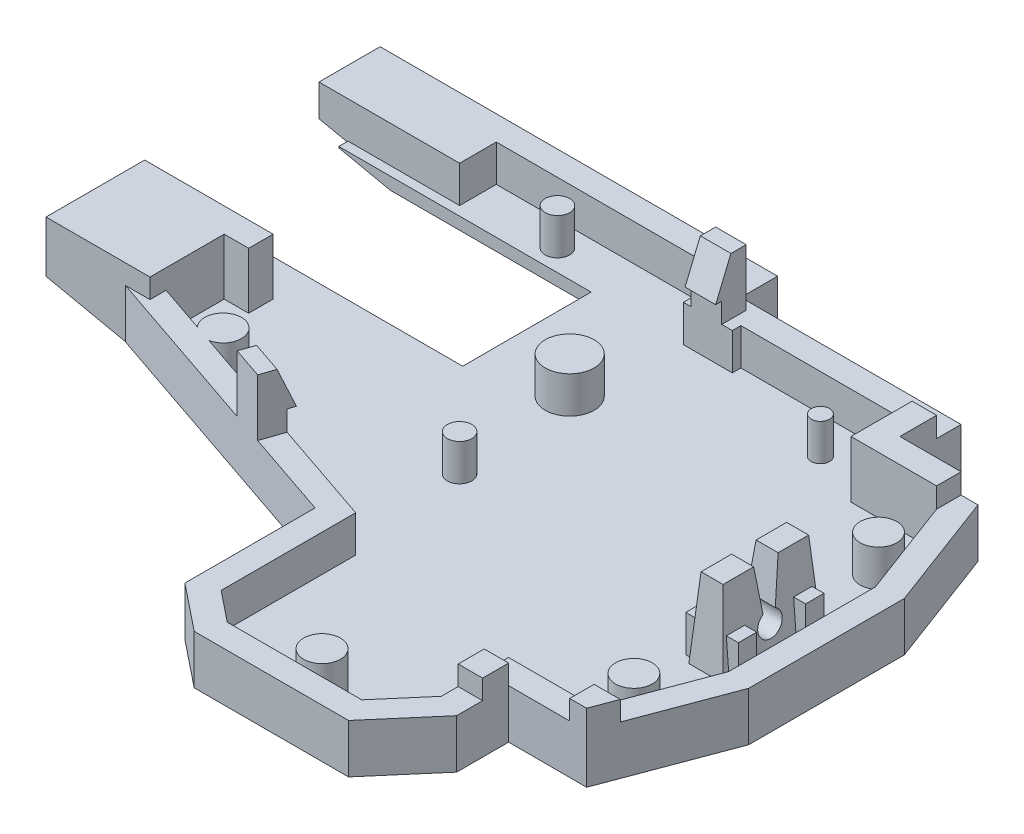
from build123d import *

# Parameters (mm, degrees)
SKETCH13_W           = 50
SKETCH13_H           = 45
BOSS_EXTRUDE4_DEPTH  = 1.6
SKETCH14_W           = 10
SKETCH14_H           = 8
CUT_EXTRUDE6_DEPTH   = 2.6
SKETCH15_W           = 18
SKETCH15_H           = 3
CUT_EXTRUDE7_DEPTH   = 2.6
SKETCH16_W           = 4
SKETCH16_H           = 0.7
CUT_EXTRUDE8_DEPTH   = 2.6
CUT_EXTRUDE9_DEPTH   = 2.6
SKETCH18_W           = 21.109590793
SKETCH18_H           = 22.840524871
CUT_EXTRUDE10_DEPTH  = 2.6
CUT_EXTRUDE11_DEPTH  = 2.6
SKETCH22_W           = 2
SKETCH22_H           = 3
CUT_EXTRUDE12_DEPTH  = 2.6
CUT_EXTRUDE13_DEPTH  = 2.6
CUT_EXTRUDE14_DEPTH  = 2.6
SKETCH25_W           = 2.8
SKETCH25_H           = 8
CUT_EXTRUDE15_DEPTH  = 2.6
BOSS_EXTRUDE6_DEPTH  = 6
SKETCH30_W           = 2.8
SKETCH30_H           = 8
BOSS_EXTRUDE7_DEPTH  = 3.5
CUT_EXTRUDE16_DEPTH  = 4.6
SKETCH32_W           = 2.8
SKETCH32_H           = 8
BOSS_EXTRUDE8_DEPTH  = 4.6
CUT_EXTRUDE18_DEPTH  = 4.6
SKETCH37_R           = 1
CUT_EXTRUDE19_DEPTH  = 4.6
CUT_EXTRUDE20_DEPTH  = 4.6
CUT_EXTRUDE21_START  = 6
CUT_EXTRUDE21_DEPTH  = 20.059798
BOSS_EXTRUDE9_DEPTH  = 4.6
SKETCH44_W           = 4.3
SKETCH44_H           = 1.5
BOSS_EXTRUDE11_DEPTH = 3
SKETCH45_R           = 1.5
SKETCH45_R_2         = 1
SKETCH45_R_3         = 1.999622229
SKETCH45_R_4         = 1.503341979
SKETCH45_R_5         = 0.75
BOSS_EXTRUDE12_DEPTH = 3
SKETCH46_W           = 2.5
SKETCH46_H           = 2
SKETCH46_W_2         = 2
BOSS_EXTRUDE13_DEPTH = 1.65
SKETCH47_W           = 3
SKETCH47_H           = 3
BOSS_EXTRUDE14_DEPTH = 3
SKETCH48_W           = 2
SKETCH48_H           = 16.336241737
CUT_EXTRUDE22_DEPTH  = 3
SKETCH49_W           = 21.336241737
SKETCH49_H           = 3
BOSS_EXTRUDE15_DEPTH = 13
SKETCH50_W           = 67
SKETCH50_H           = 49
BOSS_EXTRUDE16_DEPTH = 3
SKETCH51_W           = 5
SKETCH51_H           = 11
BOSS_EXTRUDE17_DEPTH = 15.6
CUT_EXTRUDE23_DEPTH  = 1.65
SKETCH53_W           = 2
SKETCH53_H           = 2.129349353
BOSS_EXTRUDE18_DEPTH = 1.6
SKETCH55_W           = 2.5
SKETCH55_H           = 2.5
BOSS_EXTRUDE20_DEPTH = 3
CUT_EXTRUDE24_DEPTH  = 3
SKETCH58_W           = 20
SKETCH58_H           = 10.5
SKETCH58_W_2         = 2
SKETCH58_H_2         = 2
CUT_EXTRUDE29_DEPTH  = 1
BOSS_EXTRUDE21_DEPTH = 3
BOSS_EXTRUDE22_REACH = 41.731
SKETCH61_W           = 2.5
SKETCH61_H           = 1.65
CUT_EXTRUDE30_DEPTH  = 3
CUT_EXTRUDE31_REACH  = 43.731
SKETCH64_W           = 2.551500858
SKETCH64_H           = 4.310788114
CUT_EXTRUDE32_DEPTH  = 4.65
SKETCH65_W           = 2
SKETCH65_H           = 2
BOSS_EXTRUDE23_DEPTH = 4
SKETCH66_W           = 2
SKETCH66_H           = 2
BOSS_EXTRUDE24_DEPTH = 1.6
SKETCH67_W           = 2.5
SKETCH67_H           = 2
BOSS_EXTRUDE25_DEPTH = 3
CUT_EXTRUDE33_DEPTH  = 3
BOSS_EXTRUDE26_DEPTH = 1.65
SKETCH70_W           = 5.055009343
SKETCH70_H           = 5.560438358
CUT_EXTRUDE34_DEPTH  = 3
BOSS_EXTRUDE27_DEPTH = 3
CUT_EXTRUDE35_DEPTH  = 3
BOSS_EXTRUDE28_REACH = 39.863
CUT_EXTRUDE36_DEPTH  = 3
FILLET8_R            = 1
SKETCH76_W           = 7
SKETCH76_H           = 14.5
BOSS_EXTRUDE29_DEPTH = 14.5
BOSS_EXTRUDE30_DEPTH = 2
CUT_EXTRUDE37_DEPTH  = 2
BOSS_EXTRUDE31_DEPTH = 2.684479
SKETCH85_W           = 30.566158209
SKETCH85_H           = 1.725230041
BOSS_EXTRUDE33_DEPTH = 3
BOSS_EXTRUDE34_DEPTH = 3
BOSS_EXTRUDE35_DEPTH = 3
SKETCH88_W           = 27.09375
SKETCH88_H           = 14.5
BOSS_EXTRUDE36_DEPTH = 1.6
SKETCH90_W           = 7
SKETCH90_H           = 14.5
BOSS_EXTRUDE37_DEPTH = 1.6
SKETCH93_W           = 5
SKETCH93_H           = 11
BOSS_EXTRUDE38_DEPTH = 0.5
SKETCH94_W           = 8.605758832
SKETCH94_H           = 2
BOSS_EXTRUDE39_DEPTH = 15.6
SKETCH96_W           = 8.605758832
SKETCH96_H           = 2
BOSS_EXTRUDE40_DEPTH = 0.5
SKETCH97_W           = 2
SKETCH97_H           = 49
BOSS_EXTRUDE41_DEPTH = 19.1
SKETCH98_W           = 69
SKETCH98_H           = 2
BOSS_EXTRUDE42_DEPTH = 19.1
SKETCH99_W           = 2
SKETCH99_H           = 3
BOSS_EXTRUDE43_DEPTH = 2.087376
SKETCH100_W          = 2
SKETCH100_H          = 51
BOSS_EXTRUDE45_DEPTH = 19.1
SKETCH101_W          = 71
SKETCH101_H          = 2
BOSS_EXTRUDE46_DEPTH = 19.1
BOSS_EXTRUDE47_DEPTH = 16.1
BOSS_EXTRUDE48_DEPTH = 16.1
FILLET9_R            = 2
SKETCH105_OUTSIDE_W  = 91.128
SKETCH105_OUTSIDE_H  = 73.128
CUT_EXTRUDE38_DEPTH  = 3
SKETCH106_W          = 77.0560479
SKETCH106_H          = 58.523580684
CUT_EXTRUDE39_DEPTH  = 20.1
SKETCH107_W          = 13.37564089
SKETCH107_H          = 6.179627402
CUT_EXTRUDE40_DEPTH  = 11.5
CUT_EXTRUDE41_DEPTH  = 4
SKETCH114_W          = 66.336817547
SKETCH114_H          = 51.668552302
CUT_EXTRUDE42_DEPTH  = 2
BOSS_EXTRUDE49_DEPTH = 6.5
SKETCH116_W          = 0.628599621
SKETCH116_H          = 10.5
CUT_EXTRUDE43_DEPTH  = 6.5
SKETCH117_W          = 8.5
SKETCH117_H          = 8.070282703
BOSS_EXTRUDE50_DEPTH = 1.6
SKETCH121_W          = 19.441580634
SKETCH121_H          = 74.526099825
CUT_EXTRUDE44_DEPTH  = 2.369406641


with BuildPart() as part:
    # Sketch13 → Boss-Extrude4 (new body)
    with BuildSketch(Plane(origin=(0, 0, 0), x_dir=(1, 0, 0), z_dir=(0, 1, 0))):
        with Locations((25, -22.5)):
            Rectangle(SKETCH13_W, SKETCH13_H)
    extrude(amount=BOSS_EXTRUDE4_DEPTH)

    # Sketch14 → Cut-Extrude6 (cut, through all)
    with BuildSketch(Plane(origin=(0, 1.6, 0), x_dir=(1, 0, 0), z_dir=(0, 1, 0))):
        with Locations((45, -4)):
            Rectangle(SKETCH14_W, SKETCH14_H)
    extrude(amount=-CUT_EXTRUDE6_DEPTH, mode=Mode.SUBTRACT)

    # Sketch15 → Cut-Extrude7 (cut, through all)
    with BuildSketch(Plane(origin=(0, 1.6, 0), x_dir=(1, 0, 0), z_dir=(0, 1, 0))):
        with Locations((31, -1.5)):
            Rectangle(SKETCH15_W, SKETCH15_H)
    extrude(amount=-CUT_EXTRUDE7_DEPTH, mode=Mode.SUBTRACT)

    # Sketch16 → Cut-Extrude8 (cut, through all)
    with BuildSketch(Plane(origin=(0, 1.6, 0), x_dir=(1, 0, 0), z_dir=(0, 1, 0))):
        with Locations((24, -3.35)):
            Rectangle(SKETCH16_W, SKETCH16_H)
    extrude(amount=-CUT_EXTRUDE8_DEPTH, mode=Mode.SUBTRACT)

    # Sketch17 → Cut-Extrude9 (cut, through all)
    with BuildSketch(Plane(origin=(0, 1.6, 0), x_dir=(1, 0, 0), z_dir=(0, 1, 0))):
        Polygon((47, -8), (50, -16), (65.881056194, -16), (65.881056194, 17.957346821), (47, 17.957346821), align=None)
    extrude(amount=-CUT_EXTRUDE9_DEPTH, mode=Mode.SUBTRACT)

    # Sketch18 → Cut-Extrude10 (cut, through all)
    with BuildSketch(Plane(origin=(0, 1.6, 0), x_dir=(1, 0, 0), z_dir=(0, 1, 0))):
        with Locations((50.554795396, -47.420262436)):
            Rectangle(SKETCH18_W, SKETCH18_H)
    extrude(amount=-CUT_EXTRUDE10_DEPTH, mode=Mode.SUBTRACT)

    # Sketch21 → Cut-Extrude11 (cut, through all)
    with BuildSketch(Plane(origin=(0, 1.6, 0), x_dir=(1, 0, 0), z_dir=(0, 1, 0))):
        Polygon((50, -28), (47, -36), (47, -49.297594069), (75.196774358, -49.297594069), (75.196774358, -28), align=None)
    extrude(amount=-CUT_EXTRUDE11_DEPTH, mode=Mode.SUBTRACT)

    # Sketch22 → Cut-Extrude12 (cut, through all)
    with BuildSketch(Plane(origin=(0, 1.6, 0), x_dir=(1, 0, 0), z_dir=(0, 1, 0))):
        with Locations((1, -20.836241737)):
            Rectangle(SKETCH22_W, SKETCH22_H)
    extrude(amount=-CUT_EXTRUDE12_DEPTH, mode=Mode.SUBTRACT)

    # Sketch23 → Cut-Extrude13 (cut, through all)
    with BuildSketch(Plane(origin=(0, 1.6, 0), x_dir=(1, 0, 0), z_dir=(0, 1, 0))):
        Polygon((23.5, -45), (23.5, -32), (0, -26.336241737), (-30.2261683, -26.336241737), (-30.2261683, -63.188280898), (23.5, -63.188280898), align=None)
    extrude(amount=-CUT_EXTRUDE13_DEPTH, mode=Mode.SUBTRACT)

    # Sketch24 → Cut-Extrude14 (cut, through all)
    with BuildSketch(Plane(origin=(0, 1.6, 0), x_dir=(1, 0, 0), z_dir=(0, 1, 0))):
        Polygon((23.5, -43), (7.491129632, -43), (7.491129632, -69.550234766), (44.754002286, -69.550234766), (44.754002286, -41.5), (40, -41.5), (37, -45), (26, -45), align=None)
    extrude(amount=-CUT_EXTRUDE14_DEPTH, mode=Mode.SUBTRACT)

    # Sketch25 → Cut-Extrude15 (cut, through all)
    with BuildSketch(Plane(origin=(0, 1.6, 0), x_dir=(1, 0, 0), z_dir=(0, 1, 0))):
        with Locations((46.200745069, -22.059797812)):
            Rectangle(SKETCH25_W, SKETCH25_H)
    extrude(amount=-CUT_EXTRUDE15_DEPTH, mode=Mode.SUBTRACT)

    # Sketch28 → Boss-Extrude6 (add)
    with BuildSketch(Plane.XZ):
        Polygon((42, 38), (42, 42.239848152), (37.919869845, 47), (25.298437881, 47), (21.5, 43.961249695), (21.5, 33.575244456), (-2, 27.911486193), (-2, -2), (24, -2), (24, 1), (42, 1), (42, 6), (48.386000936, 6), (52, 15.637330836), (52, 28.362669164), (48.386000936, 38), align=None)
    extrude(amount=BOSS_EXTRUDE6_DEPTH)

    # Sketch30 → Boss-Extrude7 (add)
    with BuildSketch(Plane(origin=(0, 0, 0), x_dir=(1, 0, 0), z_dir=(0, 1, 0))):
        with Locations((46.200745069, -22.059797812)):
            Rectangle(SKETCH30_W, SKETCH30_H)
    extrude(amount=BOSS_EXTRUDE7_DEPTH)

    # Sketch31 → Cut-Extrude16 (cut)
    with BuildSketch(Plane(origin=(0, 1.6, 0), x_dir=(1, 0, 0), z_dir=(0, 1, 0))):
        Polygon((37, -45), (40, -41.5), (40, -36), (47, -36), (50, -28), (50, -16), (47, -8), (40, -8), (40, -3), (26, -3), (26, -3.7), (22, -3.7), (22, 0), (0, 0), (0, -19.336241737), (2, -19.336241737), (2, -22.336241737), (0, -22.336241737), (0, -26.336241737), (23.5, -32), (23.5, -43), (26, -45), align=None)
    extrude(amount=-CUT_EXTRUDE16_DEPTH, mode=Mode.SUBTRACT)

    # Sketch32 → Boss-Extrude8 (add)
    with BuildSketch(Plane.XZ.offset(-1.6)):
        with Locations((46.200745069, 22.059797812)):
            Rectangle(SKETCH32_W, SKETCH32_H)
    extrude(amount=BOSS_EXTRUDE8_DEPTH)

    # Sketch35 → Cut-Extrude18 (cut)
    with BuildSketch(Plane(origin=(47.600745069, 0, 0), x_dir=(0, 0, -1), z_dir=(1, 0, 0))):
        Polygon((-22.059797812, 0), (-21.559797812, 0), (-21.059797812, 3.5), (-21.297672794, 5.165124873), (-23.257672794, 4.885124873), (-23.059797812, 3.5), (-22.559797812, 0), align=None)
    extrude(amount=-CUT_EXTRUDE18_DEPTH, mode=Mode.SUBTRACT)

    # Sketch37 → Cut-Extrude19 (cut)
    with BuildSketch(Plane(origin=(47.600745069, 0, 0), x_dir=(0, 0, -1), z_dir=(1, 0, 0))):
        with Locations((-22.059797812, -0.866025404)):
            Circle(SKETCH37_R)
    extrude(amount=-CUT_EXTRUDE19_DEPTH, mode=Mode.SUBTRACT)

    # Sketch39 → Cut-Extrude20 (cut)
    with BuildSketch(Plane.ZY.offset(-44.800745069)):
        Polygon((25.559797812, 3.5), (26.059797812, -3), (27.906381513, -2.8579551), (27.406381513, 3.6420449), align=None)
        Polygon((18.559797812, 3.5), (18.059797812, -3), (15.957253652, -2.838265834), (16.455739093, 3.6420449), align=None)
    extrude(amount=-CUT_EXTRUDE20_DEPTH, mode=Mode.SUBTRACT)

    # Sketch41 → Cut-Extrude21 (cut)
    with BuildSketch(Plane.XY.offset(CUT_EXTRUDE21_START)):
        Polygon((45.300745069, 3.5), (44.800745069, -3), (43.414957387, -2.893400947), (43.940591177, 3.939838325), align=None)
        Polygon((47.100745069, 3.5), (47.600745069, -3), (49.658968536, -2.841675118), (49.137313656, 3.939838325), align=None)
    extrude(amount=CUT_EXTRUDE21_DEPTH, mode=Mode.SUBTRACT)

    # Sketch43 → Boss-Extrude9 (add)
    with BuildSketch(Plane(origin=(0, 0, 0), x_dir=(1, 0, 0), z_dir=(0, 1, 0))):
        Polygon((47, -8), (50, -16), (51.170411472, -13.425094762), (48.386000936, -6), (42.818763345, -6), (42.818763345, -8), align=None)
    extrude(amount=-BOSS_EXTRUDE9_DEPTH)

    # Sketch44 → Boss-Extrude11 (add)
    with BuildSketch(Plane(origin=(0, -3, 0), x_dir=(1, 0, 0), z_dir=(0, 1, 0))):
        with Locations((46.200745069, -19.309797812)):
            Rectangle(SKETCH44_W, SKETCH44_H)
        with Locations((46.200745069, -24.809797812)):
            Rectangle(SKETCH44_W, SKETCH44_H)
    extrude(amount=BOSS_EXTRUDE11_DEPTH)

    # Sketch45 → Boss-Extrude12 (add)
    with BuildSketch(Plane(origin=(0, -3, 0), x_dir=(1, 0, 0), z_dir=(0, 1, 0))):
        with Locations((46.25, -12)):
            Circle(SKETCH45_R)
        with Locations((46.25, -32)):
            Circle(SKETCH45_R)
        with Locations((22, -22)):
            Circle(SKETCH45_R_2)
        with Locations((21, -12)):
            Circle(SKETCH45_R_3)
        with Locations((31.75, -43)):
            Circle(SKETCH45_R_4)
        with Locations((35.5, -6)):
            Circle(SKETCH45_R_5)
        with Locations((10, -2)):
            Circle(SKETCH45_R_2)
        with Locations((5, -24.336241737)):
            Circle(SKETCH45_R)
    extrude(amount=BOSS_EXTRUDE12_DEPTH)

    # Sketch46 → Boss-Extrude13 (add)
    with BuildSketch(Plane(origin=(0, 0, 0), x_dir=(1, 0, 0), z_dir=(0, 1, 0))):
        Polygon((14.137316506, -29.743490383), (16.567726059, -30.329245795), (16.099121729, -32.273573438), (13.668712176, -31.687818026), align=None)
        with Locations((23.883625006, -2.7)):
            Rectangle(SKETCH46_W, SKETCH46_H)
        with Locations((1, -20.932723283)):
            Rectangle(SKETCH46_W_2, SKETCH46_H)
        Polygon((47, -36), (48.872658355, -36.702246883), (49.750466959, -34.361423939), (47.877808604, -33.659177056), align=None)
        Polygon((40, -3), (40, -8), (47, -8), (47, -6), (42, -6), (42, -3), align=None)
    extrude(amount=BOSS_EXTRUDE13_DEPTH)

    # Sketch47 → Boss-Extrude14 (add)
    with BuildSketch(Plane(origin=(0, 0, 0), x_dir=(1, 0, 0), z_dir=(0, 1, 0))):
        with Locations((1.5, -1.5)):
            Rectangle(SKETCH47_W, SKETCH47_H)
    extrude(amount=-BOSS_EXTRUDE14_DEPTH)

    # Sketch48 → Cut-Extrude22 (cut)
    with BuildSketch(Plane(origin=(0, 0, 0), x_dir=(1, 0, 0), z_dir=(0, 1, 0))):
        with Locations((-1, -11.168120869)):
            Rectangle(SKETCH48_W, SKETCH48_H)
    extrude(amount=-CUT_EXTRUDE22_DEPTH, mode=Mode.SUBTRACT)

    # Sketch49 → Boss-Extrude15 (add)
    with BuildSketch(Plane.ZY.offset(2)):
        with Locations((8.668120869, -4.5)):
            Rectangle(SKETCH49_W, SKETCH49_H)
    extrude(amount=BOSS_EXTRUDE15_DEPTH)

    # Sketch50 → Boss-Extrude16 (add)
    with BuildSketch(Plane.XZ.offset(6)):
        with Locations((18.5, 22.5)):
            Rectangle(SKETCH50_W, SKETCH50_H)
    extrude(amount=-BOSS_EXTRUDE16_DEPTH)

    # Sketch51 → Boss-Extrude17 (add)
    with BuildSketch(Plane(origin=(0, -3, 0), x_dir=(1, 0, 0), z_dir=(0, 1, 0))):
        with Locations((49.5, -41.5)):
            Rectangle(SKETCH51_W, SKETCH51_H)
    extrude(amount=BOSS_EXTRUDE17_DEPTH)

    # Sketch52 → Cut-Extrude23 (cut)
    with BuildSketch(Plane(origin=(0, 1.65, 0), x_dir=(1, 0, 0), z_dir=(0, 1, 0))):
        Polygon((47.877808604, -33.659177056), (47, -36), (49.136000936, -36), (49.750466959, -34.361423939), align=None)
    extrude(amount=-CUT_EXTRUDE23_DEPTH, mode=Mode.SUBTRACT)

    # Sketch53 → Boss-Extrude18 (add)
    with BuildSketch(Plane(origin=(0, 0, 0), x_dir=(1, 0, 0), z_dir=(0, 1, 0))):
        with Locations((41, -39.055249399)):
            Rectangle(SKETCH53_W, SKETCH53_H)
    extrude(amount=BOSS_EXTRUDE18_DEPTH)

    # Sketch55 → Boss-Extrude20 (add)
    with BuildSketch(Plane(origin=(0, 1.65, 0), x_dir=(1, 0, 0), z_dir=(0, 1, 0))):
        with Locations((23.883625006, -2.95)):
            Rectangle(SKETCH55_W, SKETCH55_H)
    extrude(amount=BOSS_EXTRUDE20_DEPTH)

    # Sketch56 → Cut-Extrude24 (cut)
    with BuildSketch(Plane(origin=(25.133625006, 0, 0), x_dir=(0, 0, -1), z_dir=(1, 0, 0))):
        Polygon((-4.2, 1.65), (-2.95, 4.65), (-2.95, 7.68728323), (-6.59715338, 7.68728323), (-6.59715338, 1.641289328), align=None)
    extrude(amount=-CUT_EXTRUDE24_DEPTH, mode=Mode.SUBTRACT)

    # Sketch58 → Cut-Extrude29 (cut)
    with BuildSketch(Plane(origin=(0, -3, 0), x_dir=(1, 0, 0), z_dir=(0, 1, 0))):
        with Locations((4.5, -9)):
            Rectangle(SKETCH58_W, SKETCH58_H)
        with Locations((1, -18.248866233)):
            Rectangle(SKETCH58_W_2, SKETCH58_H_2)
    extrude(amount=-CUT_EXTRUDE29_DEPTH, mode=Mode.SUBTRACT)

    # Sketch60 → Boss-Extrude21 (add)
    with BuildSketch(Plane(origin=(0, -3, 0), x_dir=(1, 0, 0), z_dir=(0, 1, 0))):
        Polygon((0, -24), (23.5, -32), (0, -26.336241737), align=None)
    extrude(amount=BOSS_EXTRUDE21_DEPTH)

    # Boss-Extrude22: up to this face of the body (flat: up to its plane)
    boss_extrude22_end = Plane(part.part.faces().sort_by_distance((14.401539714, -1.5, 28.902651818))[0])
    # Sketch61 → Boss-Extrude22 (add, up to the picked face)
    with BuildSketch(Plane(origin=(-5.998871461, 0, 24.890447788), x_dir=(-0.972163821, 0, -0.234302165), z_dir=(0.234302165, 0, -0.972163821)), mode=Mode.PRIVATE) as boss_extrude22_sk1:
        with Locations((-21.962751827, 0.825)):
            Rectangle(SKETCH61_W, SKETCH61_H)
    boss_extrude22_tool1 = split(extrude(boss_extrude22_sk1.sketch, amount=BOSS_EXTRUDE22_REACH, mode=Mode.PRIVATE), bisect_by=boss_extrude22_end, keep=Keep.BOTH, mode=Mode.PRIVATE)
    add(boss_extrude22_tool1.solids().sort_by_distance((15.352521, 0.825, 30.036368))[0])

    # Sketch62 → Cut-Extrude30 (cut)
    with BuildSketch(Plane(origin=(0, 0, 0), x_dir=(1, 0, 0), z_dir=(0, 1, 0))):
        Polygon((0, -26), (-0.545193502, -28.262110548), (-9.931116312, -26), (-9.25988925, -22.847697277), align=None)
    extrude(amount=-CUT_EXTRUDE30_DEPTH, mode=Mode.SUBTRACT)

    # Cut-Extrude31: up to this face of the body (flat: up to its plane)
    cut_extrude31_end = Plane(part.part.faces().sort_by_distance((-1, -1.5, 25.659574468))[0])
    # Sketch63 → Cut-Extrude31 (cut, up to the picked face)
    with BuildSketch(Plane(origin=(-6.46747579, 0, 26.834775431), x_dir=(0.972163821, 0, 0.234302165), z_dir=(-0.234302165, 0, 0.972163821)), mode=Mode.PRIVATE) as cut_extrude31_sk1:
        Polygon((20.712751827, 0), (6.091856288, 0), (6.091856288, -3), (28.768274623, -3), (28.768274623, 0), (23.212751827, 0), (23.212751827, 1.65), (20.712751827, 1.65), align=None)
    cut_extrude31_tool1 = split(extrude(cut_extrude31_sk1.sketch, amount=-CUT_EXTRUDE31_REACH, mode=Mode.PRIVATE), bisect_by=cut_extrude31_end, keep=Keep.BOTH, mode=Mode.PRIVATE)
    add(cut_extrude31_tool1.solids().sort_by_distance((10.72932, -1.367082, 30.979392))[0], mode=Mode.SUBTRACT)

    # Sketch64 → Cut-Extrude32 (cut)
    with BuildSketch(Plane(origin=(0, 1.65, 0), x_dir=(1, 0, 0), z_dir=(0, 1, 0))):
        with Locations((1.275750429, -20.806985271)):
            Rectangle(SKETCH64_W, SKETCH64_H)
    extrude(amount=-CUT_EXTRUDE32_DEPTH, mode=Mode.SUBTRACT)

    # Sketch65 → Boss-Extrude23 (add)
    with BuildSketch(Plane(origin=(0, -4, 0), x_dir=(1, 0, 0), z_dir=(0, 1, 0))):
        with Locations((1, -18.248866233)):
            Rectangle(SKETCH65_W, SKETCH65_H)
    extrude(amount=BOSS_EXTRUDE23_DEPTH)

    # Sketch66 → Boss-Extrude24 (add)
    with BuildSketch(Plane(origin=(0, 0, 0), x_dir=(1, 0, 0), z_dir=(0, 1, 0))):
        with Locations((1, -18.248866233)):
            Rectangle(SKETCH66_W, SKETCH66_H)
    extrude(amount=BOSS_EXTRUDE24_DEPTH)

    # Sketch67 → Boss-Extrude25 (add)
    with BuildSketch(Plane(origin=(0, 1.6, 0), x_dir=(1, 0, 0), z_dir=(0, 1, 0))):
        with Locations((1.25, -18.248866233)):
            Rectangle(SKETCH67_W, SKETCH67_H)
    extrude(amount=BOSS_EXTRUDE25_DEPTH)

    # Sketch68 → Cut-Extrude33 (cut)
    with BuildSketch(Plane(origin=(0, 0, 17.248866233), x_dir=(-1, 0, 0), z_dir=(0, 0, -1))):
        Polygon((-2.5, 1.6), (-1.25, 4.6), (-1.25, 6.77486743), (-4.497451498, 6.77486743), (-4.497451498, 1.567063174), align=None)
    extrude(amount=-CUT_EXTRUDE33_DEPTH, mode=Mode.SUBTRACT)

    # Sketch69 → Boss-Extrude26 (add)
    with BuildSketch(Plane(origin=(0, 1.65, 0), x_dir=(1, 0, 0), z_dir=(0, 1, 0))):
        Polygon((14.344636536, -28.883280523), (16.885898362, -29.748390932), (16.275756374, -31.540683021), (13.734494548, -30.675572612), align=None)
    extrude(amount=-BOSS_EXTRUDE26_DEPTH)

    # Sketch70 → Cut-Extrude34 (cut)
    with BuildSketch(Plane.XY.offset(19.248866233)):
        with Locations((-0.027504672, 4.380219179)):
            Rectangle(SKETCH70_W, SKETCH70_H)
    extrude(amount=-CUT_EXTRUDE34_DEPTH, mode=Mode.SUBTRACT)

    # Sketch71 → Boss-Extrude27 (add)
    with BuildSketch(Plane(origin=(0, 1.65, 0), x_dir=(1, 0, 0), z_dir=(0, 1, 0))):
        Polygon((16.275756374, -31.540683021), (17.081415869, -29.174058256), (14.559846057, -28.298525857), (13.734494548, -30.675572612), align=None)
    extrude(amount=BOSS_EXTRUDE27_DEPTH)

    # Sketch72 → Cut-Extrude35 (cut)
    with BuildSketch(Plane(origin=(24.207602216, 0, 8.240885861), x_dir=(0.322263798, 0, -0.946649906), z_dir=(0.946649906, 0, 0.322263798))):
        Polygon((-22.112897557, 1.65), (-23.362897557, 4.65), (-23.362897557, 7.694800469), (-20.734818485, 7.694800469), (-20.734818485, 1.65), align=None)
    extrude(amount=-CUT_EXTRUDE35_DEPTH, mode=Mode.SUBTRACT)

    # Boss-Extrude28: up to this face of the body (flat: up to its plane)
    boss_extrude28_end = Plane(part.part.faces().sort_by_distance((14.039565542, 0.825, 29.779426567))[0])
    # Sketch73 → Boss-Extrude28 (add, up to the picked face)
    with BuildSketch(Plane(origin=(21.761963317, 0, 7.556127878), x_dir=(-0.328007452, 0, 0.944675136), z_dir=(-0.944675136, 0, -0.328007452)), mode=Mode.PRIVATE) as boss_extrude28_sk1:
        Polygon((24.473434161, 4.65), (23.223411105, 4.65), (21.973388049, 1.65), (22.580099427, 1.65), (24.473434161, 1.65), align=None)
    boss_extrude28_tool1 = split(extrude(boss_extrude28_sk1.sketch, amount=BOSS_EXTRUDE28_REACH, mode=Mode.PRIVATE), bisect_by=boss_extrude28_end, keep=Keep.BOTH, mode=Mode.PRIVATE)
    add(boss_extrude28_tool1.solids().sort_by_distance((14.053397, 2.983333, 29.757122))[0])

    # Sketch74 → Cut-Extrude36 (cut)
    with BuildSketch(Plane(origin=(0, -4, 0), x_dir=(1, 0, 0), z_dir=(0, 1, 0))):
        with BuildLine():
            Line((6.419171569, -6.169171569), (2.580828431, -6.169171569))
            ThreePointArc((2.580828431, -6.169171569), (-0.25, -9), (2.580828431, -11.830828431))
            Line((2.580828431, -11.830828431), (6.419171569, -11.830828431))
            ThreePointArc((6.419171569, -11.830828431), (9.25, -9), (6.419171569, -6.169171569))
        make_face()
    extrude(amount=-CUT_EXTRUDE36_DEPTH, mode=Mode.SUBTRACT)

    # Fillet8
    fillet8_edges = [part.edges().sort_by_distance(p)[0] for p in [
        (-0.25, -6, 9),
        (4.5, -6, 6.169171569),
        (9.25, -6, 9),
        (4.5, -6, 11.830828431),
    ]]
    fillet(fillet8_edges, radius=FILLET8_R)

    # Sketch76 → Boss-Extrude29 (add)
    with BuildSketch(Plane(origin=(0, -3, 0), x_dir=(1, 0, 0), z_dir=(0, 1, 0))):
        with Locations((-11.5, -39.75)):
            Rectangle(SKETCH76_W, SKETCH76_H)
    extrude(amount=BOSS_EXTRUDE29_DEPTH)

    # Sketch79 → Boss-Extrude30 (add)
    with BuildSketch(Plane(origin=(21.66634039, 0, 7.375775452), x_dir=(-0.322263798, 0, 0.946649906), z_dir=(-0.946649906, 0, -0.322263798))):
        Polygon((22.719597745, 0), (24.612897557, 0), (24.612897557, 4.65), (23.362851444, 4.65), (22.112805332, 1.65), (22.719597745, 1.65), align=None)
    extrude(amount=BOSS_EXTRUDE30_DEPTH)

    # Sketch80 → Cut-Extrude37 (cut)
    with BuildSketch(Plane(origin=(24.207602216, 0, 8.240885861), x_dir=(0.322263798, 0, -0.946649906), z_dir=(0.946649906, 0, 0.322263798))):
        Polygon((-22.112897557, 1.65), (-23.362897557, 4.65), (-24.612897557, 4.65), (-24.612897557, 0), (-22.719597745, 0), (-22.719597745, 1.65), align=None)
    extrude(amount=-CUT_EXTRUDE37_DEPTH, mode=Mode.SUBTRACT)

    # Sketch83 → Boss-Extrude31 (add)
    with BuildSketch(Plane(origin=(19.773040578, 0, 6.731247856), x_dir=(-0.322263798, 0, 0.946649906), z_dir=(-0.946649906, 0, -0.322263798))):
        Polygon((22.719597745, 1.65), (22.719597745, 0), (24.612897557, 0), (24.612897557, 4.65), (23.362851444, 4.65), (22.112805332, 1.65), align=None)
    extrude(amount=-BOSS_EXTRUDE31_DEPTH)

    # Sketch85 → Boss-Extrude33 (add)
    with BuildSketch(Plane(origin=(0, -3, 0), x_dir=(1, 0, 0), z_dir=(0, 1, 0))):
        with Locations((7.283079105, -33.362615021)):
            Rectangle(SKETCH85_W, SKETCH85_H)
    extrude(amount=BOSS_EXTRUDE33_DEPTH)

    # Sketch86 → Boss-Extrude34 (add)
    with BuildSketch(Plane(origin=(0, -3, 0), x_dir=(1, 0, 0), z_dir=(0, 1, 0))):
        Polygon((21.5, -43.961249695), (21.5, -34.225230041), (-8, -34.225230041), (-8, -47), (25.298437881, -47), align=None)
    extrude(amount=BOSS_EXTRUDE34_DEPTH)

    # Sketch87 → Boss-Extrude35 (add)
    with BuildSketch(Plane(origin=(0, -3, 0), x_dir=(1, 0, 0), z_dir=(0, 1, 0))):
        Polygon((37.919869845, -47), (47, -47), (47, -38), (42, -38), (42, -42.239848152), align=None)
    extrude(amount=BOSS_EXTRUDE35_DEPTH)

    # Sketch88 → Boss-Extrude36 (add)
    with BuildSketch(Plane(origin=(0, 0, 0), x_dir=(1, 0, 0), z_dir=(0, 1, 0))):
        with Locations((5.546875, -39.75)):
            Rectangle(SKETCH88_W, SKETCH88_H)
    extrude(amount=BOSS_EXTRUDE36_DEPTH)

    # Sketch90 → Boss-Extrude37 (add)
    with BuildSketch(Plane(origin=(0, 11.5, 0), x_dir=(1, 0, 0), z_dir=(0, 1, 0))):
        with Locations((-11.5, -39.75)):
            Rectangle(SKETCH90_W, SKETCH90_H)
    extrude(amount=BOSS_EXTRUDE37_DEPTH)

    # Sketch93 → Boss-Extrude38 (add)
    with BuildSketch(Plane(origin=(0, 12.6, 0), x_dir=(1, 0, 0), z_dir=(0, 1, 0))):
        with Locations((49.5, -41.5)):
            Rectangle(SKETCH93_W, SKETCH93_H)
    extrude(amount=BOSS_EXTRUDE38_DEPTH)

    # Sketch94 → Boss-Extrude39 (add)
    with BuildSketch(Plane(origin=(0, -3, 0), x_dir=(1, 0, 0), z_dir=(0, 1, 0))):
        with Locations((5.421445221, -31.5)):
            Rectangle(SKETCH94_W, SKETCH94_H)
    extrude(amount=BOSS_EXTRUDE39_DEPTH)

    # Sketch96 → Boss-Extrude40 (add)
    with BuildSketch(Plane(origin=(0, 12.6, 0), x_dir=(1, 0, 0), z_dir=(0, 1, 0))):
        with Locations((5.421445221, -31.5)):
            Rectangle(SKETCH96_W, SKETCH96_H)
    extrude(amount=BOSS_EXTRUDE40_DEPTH)

    # Sketch97 → Boss-Extrude41 (add)
    with BuildSketch(Plane.XZ.offset(6)):
        with Locations((-16, 22.5)):
            Rectangle(SKETCH97_W, SKETCH97_H)
    extrude(amount=-BOSS_EXTRUDE41_DEPTH)

    # Sketch98 → Boss-Extrude42 (add)
    with BuildSketch(Plane.XZ.offset(6)):
        with Locations((17.5, 48)):
            Rectangle(SKETCH98_W, SKETCH98_H)
    extrude(amount=-BOSS_EXTRUDE42_DEPTH)

    # Sketch99 → Boss-Extrude43 (add)
    with BuildSketch(Plane(origin=(0, 0, 19.336241737), x_dir=(-1, 0, 0), z_dir=(0, 0, -1))):
        with Locations((1, -1.5)):
            Rectangle(SKETCH99_W, SKETCH99_H)
    extrude(amount=BOSS_EXTRUDE43_DEPTH)

    # Sketch100 → Boss-Extrude45 (add)
    with BuildSketch(Plane.XZ.offset(6)):
        with Locations((53, 23.5)):
            Rectangle(SKETCH100_W, SKETCH100_H)
    extrude(amount=-BOSS_EXTRUDE45_DEPTH)

    # Sketch101 → Boss-Extrude46 (add)
    with BuildSketch(Plane.XZ.offset(6)):
        with Locations((18.5, -3)):
            Rectangle(SKETCH101_W, SKETCH101_H)
    extrude(amount=-BOSS_EXTRUDE46_DEPTH)

    # Sketch102 → Boss-Extrude47 (add)
    with BuildSketch(Plane(origin=(0, -3, 0), x_dir=(1, 0, 0), z_dir=(0, 1, 0))):
        with BuildLine():
            Line((50, 2), (50, 2.836676417))
            Line((50, 2.836676417), (52.928518438, 2.836676417))
            Line((52.928518438, 2.836676417), (52.928518438, 0))
            Line((52.928518438, 0), (52, 0))
            ThreePointArc((52, 0), (51.414213562, 1.414213562), (50, 2))
        make_face()
    extrude(amount=BOSS_EXTRUDE47_DEPTH)

    # Sketch103 → Boss-Extrude48 (add)
    with BuildSketch(Plane(origin=(0, -3, 0), x_dir=(1, 0, 0), z_dir=(0, 1, 0))):
        with BuildLine():
            Line((-13, 2), (-13, 3.319267165))
            Line((-13, 3.319267165), (-16.315139414, 3.319267165))
            Line((-16.315139414, 3.319267165), (-16.315139414, 0))
            Line((-16.315139414, 0), (-15, 0))
            ThreePointArc((-15, 0), (-14.414213562, 1.414213562), (-13, 2))
        make_face()
    extrude(amount=BOSS_EXTRUDE48_DEPTH)

    # Fillet9
    fillet9_edges = [part.edges().sort_by_distance(p)[0] for p in [
        (-17, -6, 22.5),
        (18.5, -6, 49),
        (-17, 3.55, 49),
        (54, -6, 22.5),
        (54, 3.55, 49),
        (18.5, -6, -4),
        (-17, 3.55, -4),
        (54, 3.55, -4),
    ]]
    fillet(fillet9_edges, radius=FILLET9_R)

    # Sketch105 outside → Cut-Extrude38 (cut)
    with BuildSketch(Plane(origin=(0, 13.1, 0), x_dir=(1, 0, 0), z_dir=(0, 1, 0))):
        with Locations((18.5, -22.5)):
            Rectangle(SKETCH105_OUTSIDE_W, SKETCH105_OUTSIDE_H)
        with BuildLine():
            Line((-16, 2), (-16, -47))
            ThreePointArc((-16, -47), (-15.707106781, -47.707106781), (-15, -48))
            Line((-15, -48), (52, -48))
            ThreePointArc((52, -48), (52.707106781, -47.707106781), (53, -47))
            Line((53, -47), (53, 2))
            ThreePointArc((53, 2), (52.707106781, 2.707106781), (52, 3))
            Line((52, 3), (-15, 3))
            ThreePointArc((-15, 3), (-15.707106781, 2.707106781), (-16, 2))
        make_face(mode=Mode.SUBTRACT)
    extrude(amount=-CUT_EXTRUDE38_DEPTH, mode=Mode.SUBTRACT)

    # Sketch106 → Cut-Extrude39 (cut, through all)
    with BuildSketch(Plane.XZ.offset(6)):
        with Locations((17.692589571, 21.631481201)):
            Rectangle(SKETCH106_W, SKETCH106_H)
        Polygon((-2, -2), (24, -2), (24, 1), (42, 1), (42, 6), (48.386000936, 6), (52, 15.637330836), (52, 28.362669164), (49.136000936, 36), (48.386000936, 38), (42, 37.990574723), (42, 42.239848152), (37.919869845, 47), (25.298437881, 47), (21.5, 43.961249695), (21.5, 33.319148936), (-2, 25.319148936), (-2, 17.248866233), (-8.372079234, 17.248866233), (-8.372079234, 3), (-2, 3), align=None, mode=Mode.SUBTRACT)
    extrude(amount=-CUT_EXTRUDE39_DEPTH, mode=Mode.SUBTRACT)

    # Sketch107 → Cut-Extrude40 (cut)
    with BuildSketch(Plane(origin=(0, 13.1, 0), x_dir=(1, 0, 0), z_dir=(0, 1, 0))):
        with Locations((44.784273424, -38.274312053)):
            Rectangle(SKETCH107_W, SKETCH107_H)
    extrude(amount=-CUT_EXTRUDE40_DEPTH, mode=Mode.SUBTRACT)

    # Sketch113 → Cut-Extrude41 (cut, through all)
    with BuildSketch(Plane(origin=(0, -3, 0), x_dir=(1, 0, 0), z_dir=(0, 1, 0))):
        Polygon((-6.128599621, -3), (-6.128599621, -14.861393841), (-2, -14.861393841), (-2, -17.248866233), (-9.246534053, -26.452427809), (-13.814435406, -0.657200841), (-2.974123127, 6.68981616), (-3.537653946, 5.974095989), align=None)
    extrude(amount=-CUT_EXTRUDE41_DEPTH, mode=Mode.SUBTRACT)

    # Sketch114 → Cut-Extrude42 (cut)
    with BuildSketch(Plane.XZ.offset(6)):
        with Locations((24.645555619, 22.809022442)):
            Rectangle(SKETCH114_W, SKETCH114_H)
    extrude(amount=-CUT_EXTRUDE42_DEPTH, mode=Mode.SUBTRACT)

    # Sketch115 → Boss-Extrude49 (add)
    with BuildSketch(Plane.ZY.offset(2)):
        Polygon((14.861393841, -3), (14.861393841, -4), (25.319148936, -4), (25.319148936, 0), (17.248866233, 0), (17.248866233, -3), align=None)
        Polygon((-2, 0), (-2, -4), (3, -4), (3, -3), (3, 0), align=None)
    extrude(amount=BOSS_EXTRUDE49_DEPTH)

    # Sketch116 → Cut-Extrude43 (cut)
    with BuildSketch(Plane(origin=(0, -3, 0), x_dir=(1, 0, 0), z_dir=(0, 1, 0))):
        with Locations((-5.81429981, -9)):
            Rectangle(SKETCH116_W, SKETCH116_H)
    extrude(amount=-CUT_EXTRUDE43_DEPTH, mode=Mode.SUBTRACT)

    # Sketch117 → Boss-Extrude50 (add)
    with BuildSketch(Plane(origin=(0, 0, 0), x_dir=(1, 0, 0), z_dir=(0, 1, 0))):
        with Locations((-4.25, -21.284007585)):
            Rectangle(SKETCH117_W, SKETCH117_H)
    extrude(amount=BOSS_EXTRUDE50_DEPTH)

    # Sketch121 → Cut-Extrude44 (cut, through all)
    with BuildSketch(Plane(origin=(-0.896189441, -4.216239828, 0), x_dir=(0.978147601, -0.207911691, 0), z_dir=(0.207911691, 0.978147601, 0))):
        with Locations((-1.991271406, 3.02484601)):
            Rectangle(SKETCH121_W, SKETCH121_H)
    extrude(amount=-CUT_EXTRUDE44_DEPTH, mode=Mode.SUBTRACT)


solid = part.part
